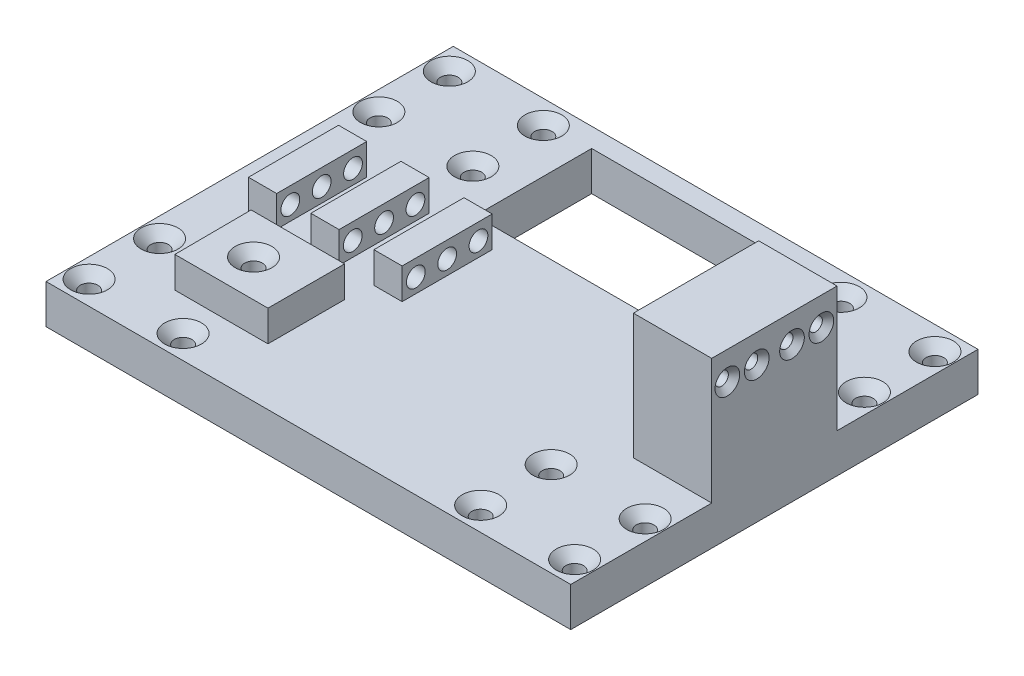
from build123d import *

# Parameters (mm, degrees)
SKETCH2_W                                       = 134
SKETCH2_H                                       = 104
BOSS_EXTRUDE1_DEPTH                             = 10
SKETCH3_W                                       = 7.2
SKETCH3_H                                       = 23
BOSS_EXTRUDE2_DEPTH                             = 7.9
BOSS_EXTRUDE3_DEPTH                             = 7.9
CSK_FOR_M4_FLAT_HEAD_MACHINE_SCREW1_D           = 4.5
CSK_FOR_M4_FLAT_HEAD_MACHINE_SCREW1_DEPTH       = 10
CSK_FOR_M4_FLAT_HEAD_MACHINE_SCREW1_CSINK_D     = 9.4
CSK_FOR_M4_FLAT_HEAD_MACHINE_SCREW1_CSINK_ANGLE = 90
CSK_FOR_M4_FLAT_HEAD_MACHINE_SCREW1_TIP         = 1.351936393
SKETCH4_R                                       = 2.4
CUT_EXTRUDE3_DEPTH                              = 124.303600725
SKETCH8_W                                       = 20
SKETCH8_H                                       = 32
BOSS_EXTRUDE4_DEPTH                             = 32
CSK_FOR_M3_FLAT_HEAD_MACHINE_SCREW1_D           = 3.4
CSK_FOR_M3_FLAT_HEAD_MACHINE_SCREW1_DEPTH       = 10
CSK_FOR_M3_FLAT_HEAD_MACHINE_SCREW1_CSINK_D     = 6.3
CSK_FOR_M3_FLAT_HEAD_MACHINE_SCREW1_CSINK_ANGLE = 90
CSK_FOR_M3_FLAT_HEAD_MACHINE_SCREW1_TIP         = 1.021463052
CSK_FOR_M4_FLAT_HEAD_MACHINE_SCREW2_D           = 4.5
CSK_FOR_M4_FLAT_HEAD_MACHINE_SCREW2_CSINK_D     = 9.4
CSK_FOR_M4_FLAT_HEAD_MACHINE_SCREW2_CSINK_ANGLE = 90
SKETCH9_W                                       = 48.824666317
SKETCH9_H                                       = 29.759338586
CUT_EXTRUDE4_DEPTH                              = 11


with BuildPart() as part:
    # Sketch2 → Boss-Extrude1 (new body)
    with BuildSketch(Plane(origin=(0, 0, 0), x_dir=(1, 0, 0), z_dir=(0, 1, 0))):
        with Locations((4.53434515, -5.431597684)):
            Rectangle(SKETCH2_W, SKETCH2_H)
    extrude(amount=BOSS_EXTRUDE1_DEPTH)

    # Sketch3 → Boss-Extrude2 (add)
    with BuildSketch(Plane(origin=(0, 10, 0), x_dir=(1, 0, 0), z_dir=(0, 1, 0))):
        with Locations((-48.169255575, -4.929066507)):
            Rectangle(SKETCH3_W, SKETCH3_H)
        with Locations((-32.22922018, -4.929066507)):
            Rectangle(SKETCH3_W, SKETCH3_H)
        with Locations((-16.128962561, -4.929066507)):
            Rectangle(SKETCH3_W, SKETCH3_H)
    extrude(amount=BOSS_EXTRUDE2_DEPTH)

    # Sketch5 → Boss-Extrude3 (add)
    with BuildSketch(Plane(origin=(0, 10, 0), x_dir=(1, 0, 0), z_dir=(0, 1, 0))):
        Polygon((-20.32922018, -42.887289811), (-20.32922018, -23.319494658), (-44.195608335, -23.319494658), (-44.100155676, -42.887289811), align=None)
    extrude(amount=BOSS_EXTRUDE3_DEPTH)

    # CSK for M4 Flat Head Machine Screw1
    with Locations(Plane(origin=(0, 10, 0), x_dir=(1, 0, 0), z_dir=(0, 1, 0))):
        with Locations((-57.46565485, 40.568402316), (-33.46565485, 40.568402316), (-57.46565485, 22.568402316), (-33.46565485, 22.568402316), (-57.46565485, -33.431597684), (-57.46565485, -51.431597684), (-33.46565485, -51.431597684), (42.53434515, -33.431597684), (66.53434515, -33.431597684), (42.53434515, -51.431597684), (66.53434515, -51.431597684), (42.53434515, 40.568402316), (66.53434515, 40.568402316), (66.53434515, 22.568402316), (42.53434515, 22.568402316)):
            CounterSinkHole(CSK_FOR_M4_FLAT_HEAD_MACHINE_SCREW1_D / 2, CSK_FOR_M4_FLAT_HEAD_MACHINE_SCREW1_CSINK_D / 2, depth=CSK_FOR_M4_FLAT_HEAD_MACHINE_SCREW1_DEPTH, counter_sink_angle=CSK_FOR_M4_FLAT_HEAD_MACHINE_SCREW1_CSINK_ANGLE)
            with Locations((0, 0, -(CSK_FOR_M4_FLAT_HEAD_MACHINE_SCREW1_DEPTH + CSK_FOR_M4_FLAT_HEAD_MACHINE_SCREW1_TIP / 2))):  # 118° drill point
                Cone(0, CSK_FOR_M4_FLAT_HEAD_MACHINE_SCREW1_D / 2, CSK_FOR_M4_FLAT_HEAD_MACHINE_SCREW1_TIP, mode=Mode.SUBTRACT)

    # Sketch4 → Cut-Extrude3 (cut, through all)
    with BuildSketch(Plane.ZY.offset(51.769255575)):
        with Locations((12.929066507, 13.7)):
            Circle(SKETCH4_R)
        with Locations((4.929066507, 13.7)):
            Circle(SKETCH4_R)
        with Locations((-3.070933493, 13.7)):
            Circle(SKETCH4_R)
    extrude(amount=-CUT_EXTRUDE3_DEPTH, mode=Mode.SUBTRACT)

    # Sketch8 → Boss-Extrude4 (add)
    with BuildSketch(Plane(origin=(0, 10, 0), x_dir=(1, 0, 0), z_dir=(0, 1, 0))):
        with Locations((61.53434515, -5.431597684)):
            Rectangle(SKETCH8_W, SKETCH8_H)
    extrude(amount=BOSS_EXTRUDE4_DEPTH)

    # CSK for M3 Flat Head Machine Screw1
    with Locations(Plane(origin=(71.53434515, 0, 0), x_dir=(0, 0, -1), z_dir=(1, 0, 0))):
        with Locations((-17.431597684, 34.83), (-9.931597684, 34.83), (-0.931597684, 34.83), (6.568402316, 34.83)):
            CounterSinkHole(CSK_FOR_M3_FLAT_HEAD_MACHINE_SCREW1_D / 2, CSK_FOR_M3_FLAT_HEAD_MACHINE_SCREW1_CSINK_D / 2, depth=CSK_FOR_M3_FLAT_HEAD_MACHINE_SCREW1_DEPTH, counter_sink_angle=CSK_FOR_M3_FLAT_HEAD_MACHINE_SCREW1_CSINK_ANGLE)
            with Locations((0, 0, -(CSK_FOR_M3_FLAT_HEAD_MACHINE_SCREW1_DEPTH + CSK_FOR_M3_FLAT_HEAD_MACHINE_SCREW1_TIP / 2))):  # 118° drill point
                Cone(0, CSK_FOR_M3_FLAT_HEAD_MACHINE_SCREW1_D / 2, CSK_FOR_M3_FLAT_HEAD_MACHINE_SCREW1_TIP, mode=Mode.SUBTRACT)

    # CSK for M4 Flat Head Machine Screw2 (through all)
    with Locations(Plane(origin=(0, 17.9, 0), x_dir=(1, 0, 0), z_dir=(0, 1, 0))):
        with Locations((-33.46565485, -33.431597684)):
            CounterSinkHole(CSK_FOR_M4_FLAT_HEAD_MACHINE_SCREW2_D / 2, CSK_FOR_M4_FLAT_HEAD_MACHINE_SCREW2_CSINK_D / 2, counter_sink_angle=CSK_FOR_M4_FLAT_HEAD_MACHINE_SCREW2_CSINK_ANGLE)

    # Sketch9 → Cut-Extrude4 (cut, through all)
    with BuildSketch(Plane(origin=(0, 10, 0), x_dir=(1, 0, 0), z_dir=(0, 1, 0))):
        with Locations((2.204099142, 26.778317221)):
            Rectangle(SKETCH9_W, SKETCH9_H)
    extrude(amount=-CUT_EXTRUDE4_DEPTH, mode=Mode.SUBTRACT)


solid = part.part
